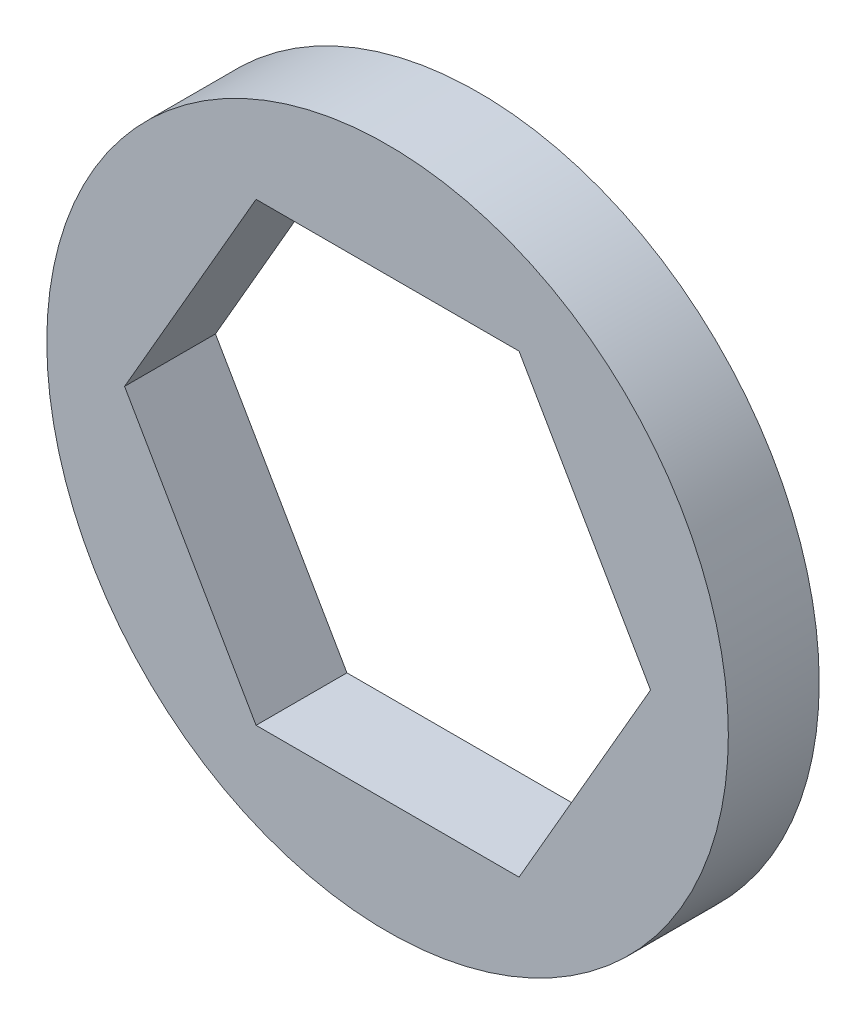
from build123d import *

# Parameters (mm, degrees)
SKETCH1_R           = 7.5
BOSS_EXTRUDE1_DEPTH = 1


with BuildPart() as part:
    # Sketch1 → Boss-Extrude1 (new, symmetric)
    with BuildSketch(Plane.XY):
        Circle(SKETCH1_R)
        Polygon((5.787936449, 0), (2.893968224, 5.0125), (-2.893968224, 5.0125), (-5.787936449, 0), (-2.893968224, -5.0125), (2.893968224, -5.0125), align=None, mode=Mode.SUBTRACT)
    extrude(amount=BOSS_EXTRUDE1_DEPTH, both=True)


solid = part.part
